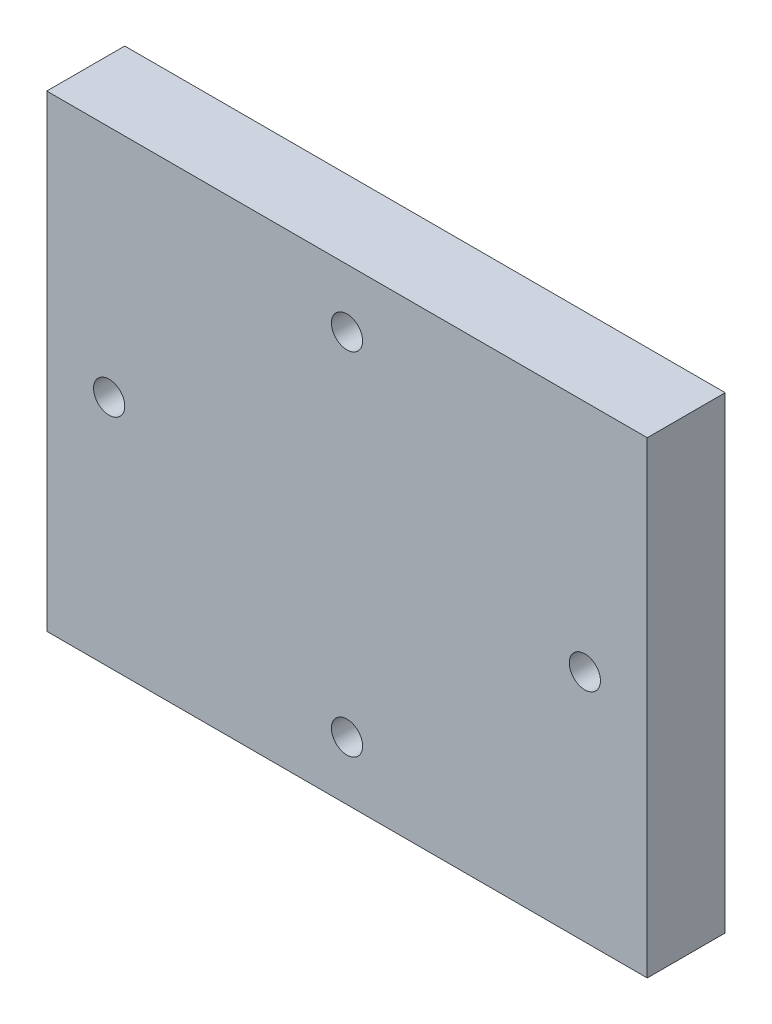
from build123d import *

# Parameters (mm, degrees)
SKETCH_1_W      = 77
SKETCH_1_H      = 60
SKETCH_1_R      = 2
EXTRUDE_1_DEPTH = 10


with BuildPart() as part:
    # 草图1 → 凸台-拉伸1 (new body)
    with BuildSketch(Plane.XY):
        with Locations((7.730258776, 0.769741224)):
            Rectangle(SKETCH_1_W, SKETCH_1_H)
        with Locations((7.730258776, 23.269741224)):
            Circle(SKETCH_1_R, mode=Mode.SUBTRACT)
        with Locations((7.730258776, -21.730258776)):
            Circle(SKETCH_1_R, mode=Mode.SUBTRACT)
        with Locations((38.230258776, 0.769741224)):
            Circle(SKETCH_1_R, mode=Mode.SUBTRACT)
        with Locations((-22.769741224, 0.769741224)):
            Circle(SKETCH_1_R, mode=Mode.SUBTRACT)
    extrude(amount=EXTRUDE_1_DEPTH)


solid = part.part
